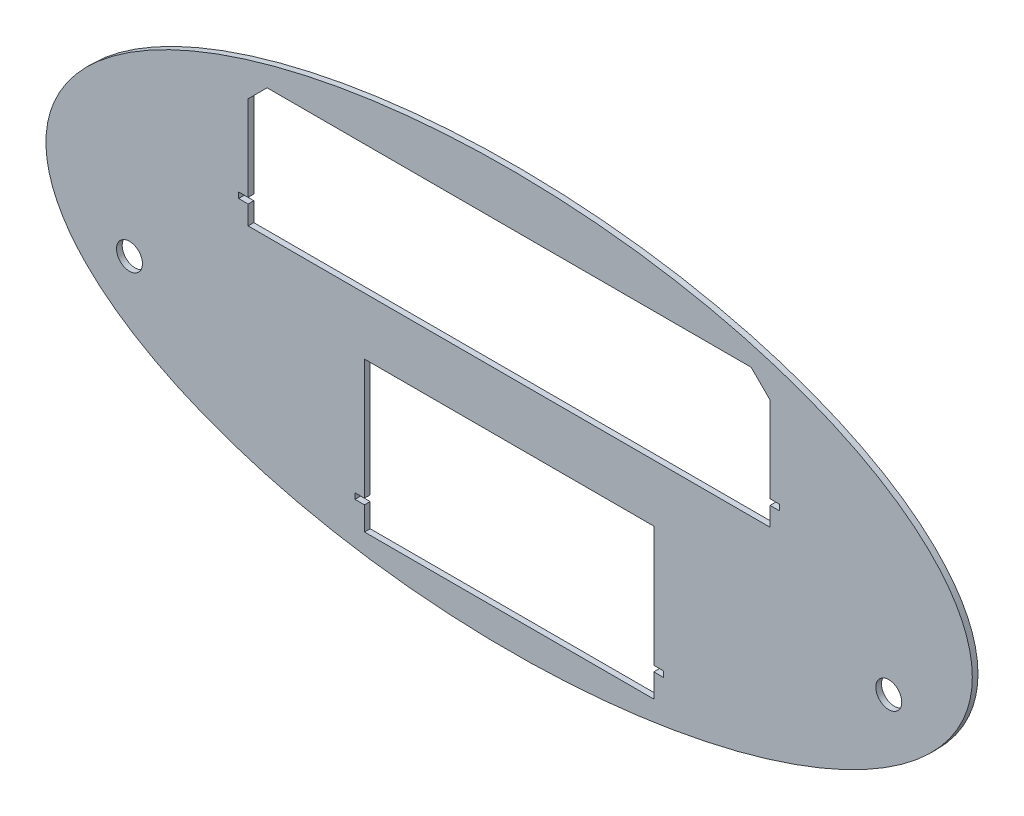
from build123d import *

# Parameters (mm, degrees)
SKETCH1_RX          = 244
SKETCH1_RY          = 110
BOSS_EXTRUDE1_DEPTH = 3
CUT_EXTRUDE5_DEPTH  = 4
CUT_EXTRUDE7_DEPTH  = 4
SKETCH12_R          = 6.83635542
CUT_EXTRUDE8_DEPTH  = 4
CHAMFER1_SIZE       = 10


with BuildPart() as part:
    # Sketch1 → Boss-Extrude1 (new body)
    with BuildSketch(Plane.XY):
        with Locations((0, 0)):
            Ellipse(SKETCH1_RX, SKETCH1_RY)
    extrude(amount=-BOSS_EXTRUDE1_DEPTH)

    # Sketch10 → Cut-Extrude5 (cut, through all)
    with BuildSketch(Plane.XY):
        Polygon((-137.5, 83.1), (137.5, 83.1), (137.5, 28.1), (142.5, 28.1), (142.5, 25.1), (137.5, 25.1), (137.5, 15.1), (-137.5, 15.1), (-137.5, 25.1), (-142.5, 25.1), (-142.5, 28.1), (-137.5, 28.1), align=None)
    extrude(amount=-CUT_EXTRUDE5_DEPTH, mode=Mode.SUBTRACT)

    # Sketch13 → Cut-Extrude7 (cut, through all)
    with BuildSketch(Plane.XY):
        Polygon((76.2, -81.5), (76.2, -93.9), (-76.2, -93.9), (-76.2, -81.5), (-81.2, -81.5), (-81.2, -78.5), (-76.2, -78.5), (-76.2, -15), (76.2, -15), (76.2, -78.5), (81.2, -78.5), (81.2, -81.5), align=None)
    extrude(amount=-CUT_EXTRUDE7_DEPTH, mode=Mode.SUBTRACT)

    # Sketch12 → Cut-Extrude8 (cut, through all)
    with BuildSketch(Plane.XY):
        with Locations((200, -30)):
            Circle(SKETCH12_R)
        with Locations((-200, -30)):
            Circle(SKETCH12_R)
    extrude(amount=-CUT_EXTRUDE8_DEPTH, mode=Mode.SUBTRACT)

    # Chamfer1
    chamfer1_edges = [part.edges().sort_by_distance(p)[0] for p in [
        (-137.5, 83.1, -1.5),
        (137.5, 83.1, -1.5),
    ]]
    chamfer(chamfer1_edges, length=CHAMFER1_SIZE)


solid = part.part
